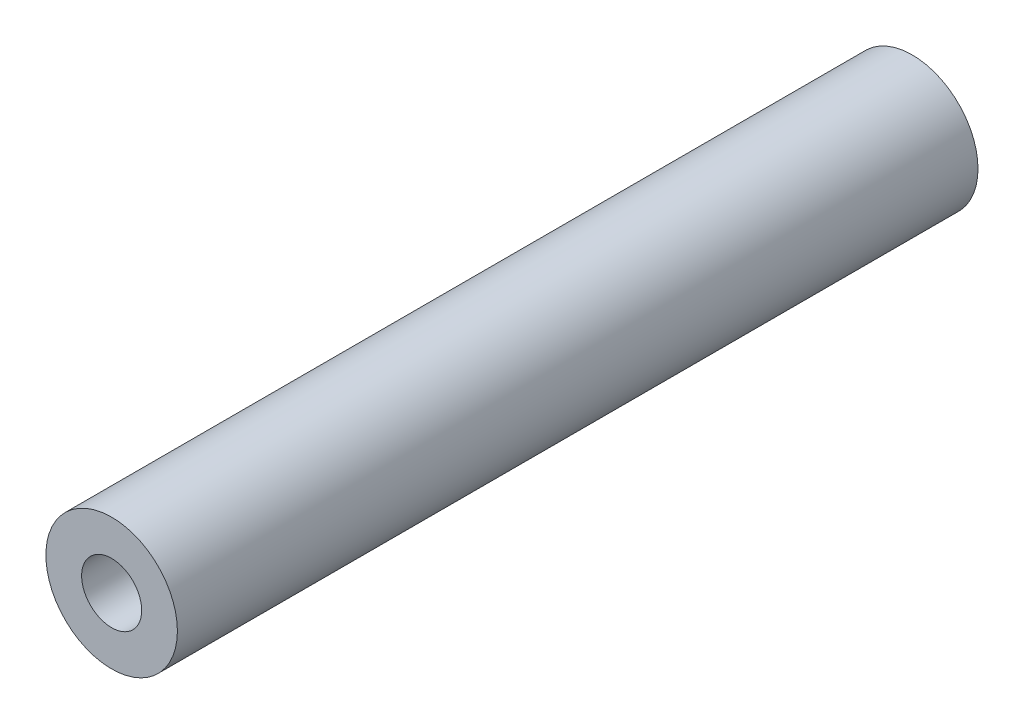
from build123d import *

# Parameters (mm, degrees)
SKETCH1_R           = 2.3
SKETCH1_R_2         = 1.05
BOSS_EXTRUDE1_DEPTH = 28


with BuildPart() as part:
    # Sketch1 → Boss-Extrude1 (new body)
    with BuildSketch(Plane.XY):
        Circle(SKETCH1_R)
        Circle(SKETCH1_R_2, mode=Mode.SUBTRACT)
    extrude(amount=BOSS_EXTRUDE1_DEPTH)


solid = part.part
